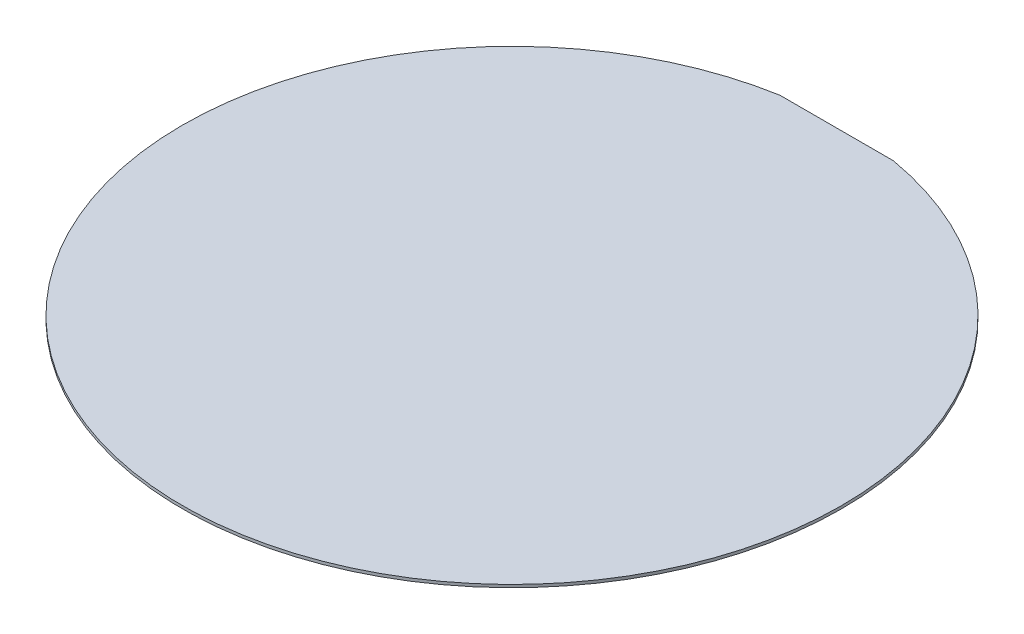
from build123d import *

# Parameters (mm, degrees)
BOSS_EXTRUDE1_DEPTH = 1.5


with BuildPart() as part:
    # Sketch2 → Boss-Extrude1 (new body)
    with BuildSketch(Plane(origin=(0, 0, 0), x_dir=(1, 0, 0), z_dir=(0, 1, 0))):
        with BuildLine():
            Line((-30.130383751, 172.386658344), (30.130383751, 172.386658344))
            ThreePointArc((30.130383751, 172.386658344), (0, -175), (-30.130383751, 172.386658344))
        make_face()
    extrude(amount=BOSS_EXTRUDE1_DEPTH)


solid = part.part
